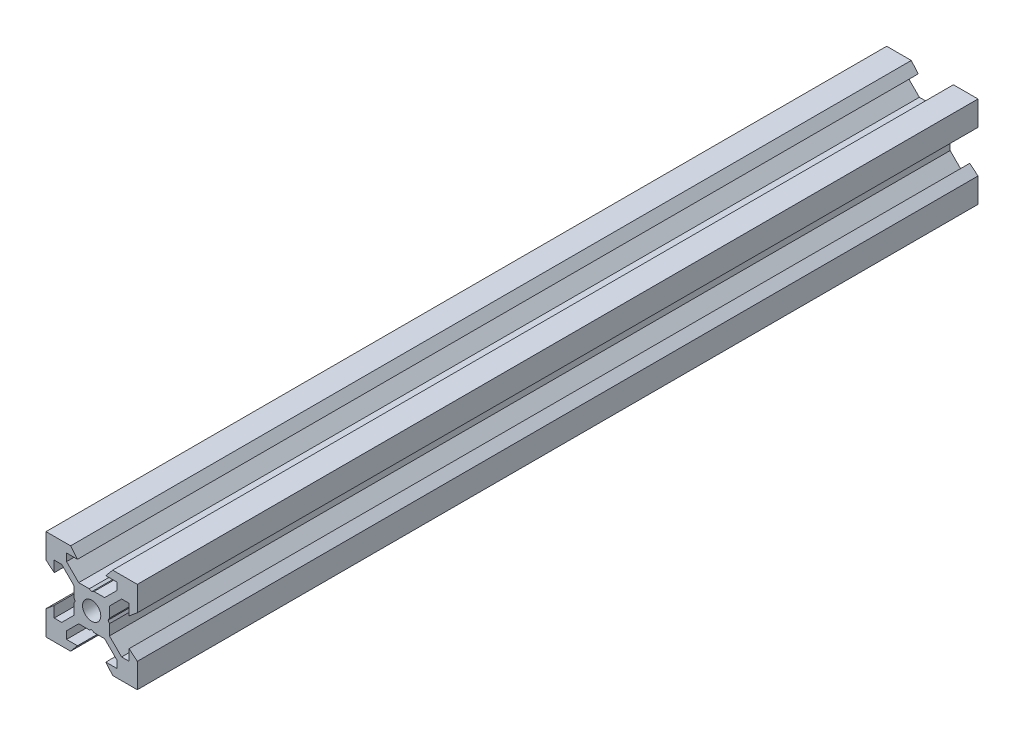
from build123d import *

# Parameters (mm, degrees)
SKETCH1_R           = 2
BOSS_EXTRUDE1_DEPTH = 92.075


with BuildPart() as part:
    # Sketch1 → Boss-Extrude1 (new body, symmetric)
    with BuildSketch(Plane.XY):
        Polygon((10, 10), (10, 4.610379336), (8.2, 3.1), (8.2, 5.5), (6.560660172, 5.5), (3.9, 2.839339828), (3.9, 0.519615242), (3.6, 0), (3.9, -0.519615242), (3.9, -2.839339828), (6.560660172, -5.5), (8.2, -5.5), (8.2, -3.1), (10, -4.610379336), (10, -10), (4.610379336, -10), (3.1, -8.2), (5.5, -8.2), (5.5, -6.560660172), (2.839339828, -3.9), (0.519615242, -3.9), (0, -3.6), (-0.519615242, -3.9), (-2.839339828, -3.9), (-5.5, -6.560660172), (-5.5, -8.2), (-3.1, -8.2), (-4.610379336, -10), (-10, -10), (-10, -4.610379336), (-8.2, -3.1), (-8.2, -5.5), (-6.560660172, -5.5), (-3.9, -2.839339828), (-3.9, -0.519615242), (-3.6, 0), (-3.9, 0.519615242), (-3.9, 2.839339828), (-6.560660172, 5.5), (-8.2, 5.5), (-8.2, 3.1), (-10, 4.610379336), (-10, 10), (-4.610379336, 10), (-3.1, 8.2), (-5.5, 8.2), (-5.5, 6.560660172), (-2.839339828, 3.9), (-0.519615242, 3.9), (0, 3.6), (0.519615242, 3.9), (2.839339828, 3.9), (5.5, 6.560660172), (5.5, 8.2), (3.1, 8.2), (4.610379336, 10), align=None)
        Circle(SKETCH1_R, mode=Mode.SUBTRACT)
    extrude(amount=BOSS_EXTRUDE1_DEPTH, both=True)


solid = part.part
